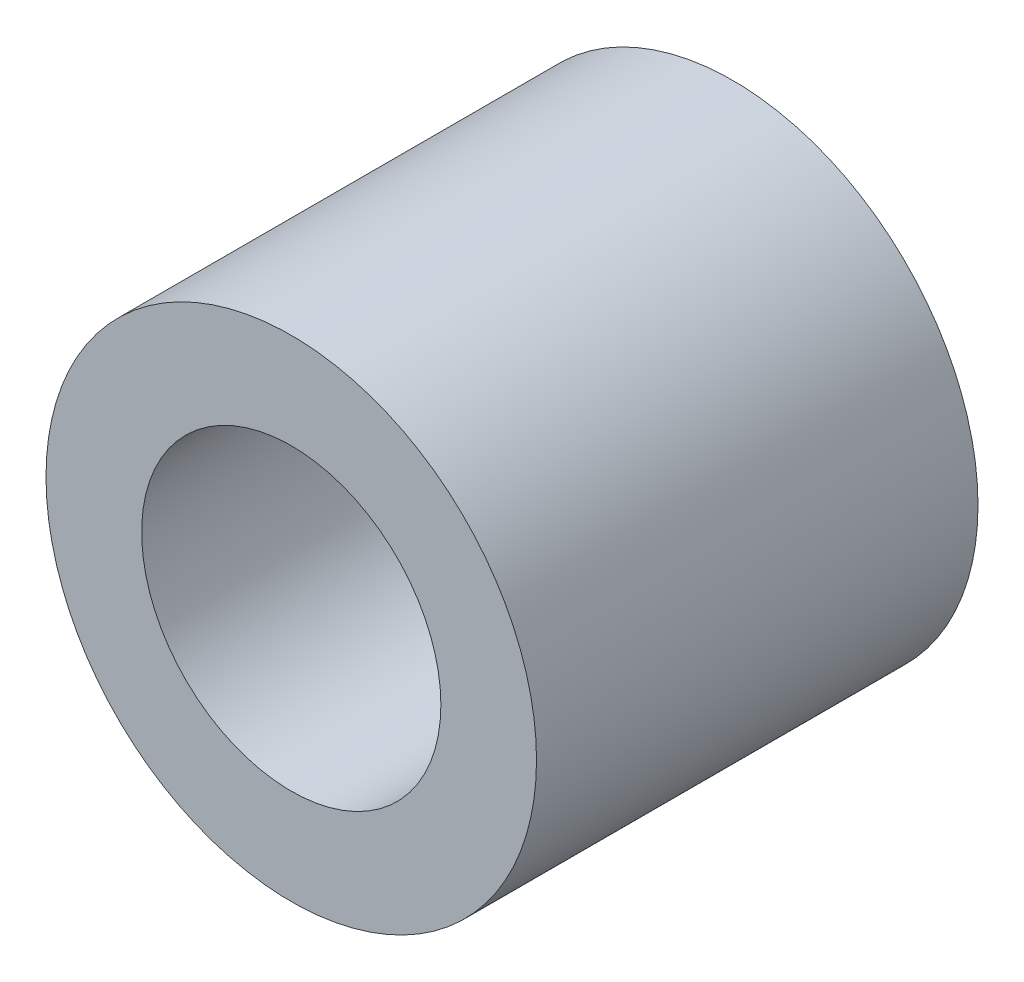
from build123d import *

# Parameters (mm, degrees)
SKETCH_1_R      = 5
SKETCH_1_R_2    = 3.05
EXTRUDE_1_DEPTH = 9


with BuildPart() as part:
    # ｽｹｯﾁ1 → ﾎﾞｽ - 押し出し1 (new body)
    with BuildSketch(Plane.XY):
        Circle(SKETCH_1_R)
        Circle(SKETCH_1_R_2, mode=Mode.SUBTRACT)
    extrude(amount=EXTRUDE_1_DEPTH)


solid = part.part
